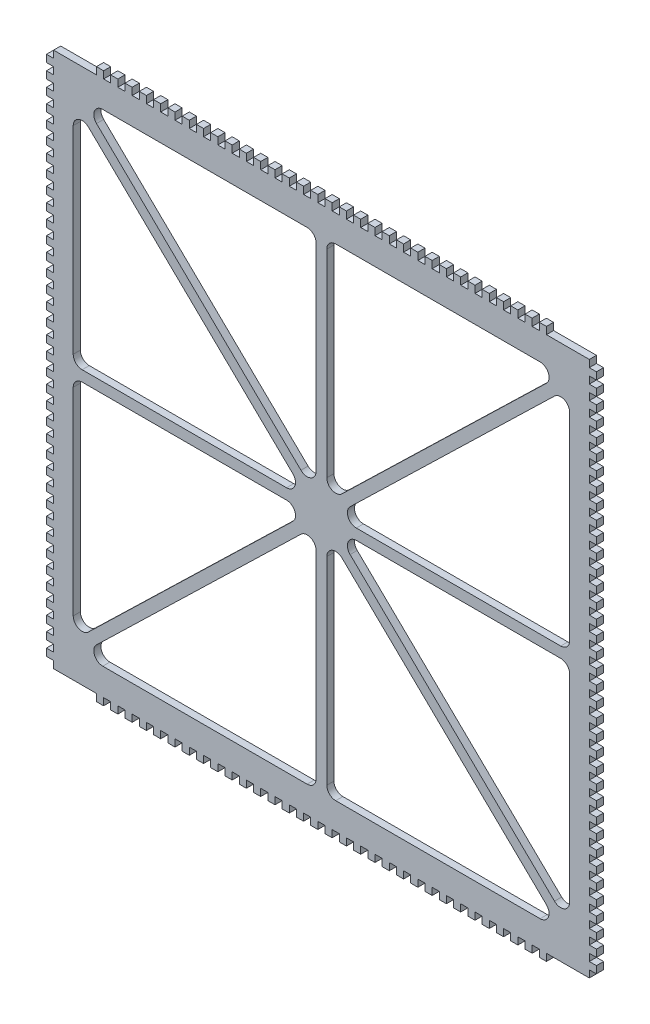
from build123d import *

# Parameters (mm, degrees)
SKETCH1_W           = 308
SKETCH1_H           = 300
BOSS_EXTRUDE1_DEPTH = 4
SKETCH2_W           = 4
SKETCH2_H           = 4
CUT_EXTRUDE1_DEPTH  = 4
SKETCH3_W           = 4
SKETCH3_H           = 4
BOSS_EXTRUDE2_DEPTH = 4


with BuildPart() as part:
    # Sketch1 → Boss-Extrude1 (new body)
    with BuildSketch(Plane.XY):
        Rectangle(SKETCH1_W, SKETCH1_H)
        with BuildLine():
            Line((-122.477093381, 135), (-8, 135))
            ThreePointArc((-8, 135), (-4.464466094, 133.535533906), (-3, 130))
            Line((-3, 130), (-3, 19.113899965))
            ThreePointArc((-3, 19.113899965), (-6.049843741, 14.509891867), (-11.478756226, 15.522485881))
            Line((-11.478756226, 15.522485881), (-125.955849607, 126.408585916))
            ThreePointArc((-125.955849607, 126.408585916), (-127.111587443, 131.876556631), (-122.477093381, 135))
        make_face(mode=Mode.SUBTRACT)
        with BuildLine():
            Line((-130.521243774, 122.477514119), (-16.044150393, 11.591414084))
            ThreePointArc((-16.044150393, 11.591414084), (-14.888412557, 6.123443369), (-19.522906619, 3))
            Line((-19.522906619, 3), (-134, 3))
            ThreePointArc((-134, 3), (-137.535533906, 4.464466094), (-139, 8))
            Line((-139, 8), (-139, 118.886100035))
            ThreePointArc((-139, 118.886100035), (-135.950156259, 123.490108133), (-130.521243774, 122.477514119))
        make_face(mode=Mode.SUBTRACT)
        with BuildLine():
            Line((8, 135), (122.477093381, 135))
            ThreePointArc((122.477093381, 135), (127.111587443, 131.876556631), (125.955849607, 126.408585916))
            Line((125.955849607, 126.408585916), (11.478756226, 15.522485881))
            ThreePointArc((11.478756226, 15.522485881), (6.049843741, 14.509891867), (3, 19.113899965))
            Line((3, 19.113899965), (3, 130))
            ThreePointArc((3, 130), (4.464466094, 133.535533906), (8, 135))
        make_face(mode=Mode.SUBTRACT)
        with BuildLine():
            Line((130.521243774, 122.477514119), (16.044150393, 11.591414084))
            ThreePointArc((16.044150393, 11.591414084), (14.888412557, 6.123443369), (19.522906619, 3))
            Line((19.522906619, 3), (134, 3))
            ThreePointArc((134, 3), (137.535533906, 4.464466094), (139, 8))
            Line((139, 8), (139, 118.886100035))
            ThreePointArc((139, 118.886100035), (135.950156259, 123.490108133), (130.521243774, 122.477514119))
        make_face(mode=Mode.SUBTRACT)
        with BuildLine():
            Line((-139, -8), (-139, -118.886100035))
            ThreePointArc((-139, -118.886100035), (-135.950156259, -123.490108133), (-130.521243774, -122.477514119))
            Line((-130.521243774, -122.477514119), (-16.044150393, -11.591414084))
            ThreePointArc((-16.044150393, -11.591414084), (-14.888412557, -6.123443369), (-19.522906619, -3))
            Line((-19.522906619, -3), (-134, -3))
            ThreePointArc((-134, -3), (-137.535533906, -4.464466094), (-139, -8))
        make_face(mode=Mode.SUBTRACT)
        with BuildLine():
            Line((139, -8), (139, -118.886100035))
            ThreePointArc((139, -118.886100035), (135.950156259, -123.490108133), (130.521243774, -122.477514119))
            Line((130.521243774, -122.477514119), (16.044150393, -11.591414084))
            ThreePointArc((16.044150393, -11.591414084), (14.888412557, -6.123443369), (19.522906619, -3))
            Line((19.522906619, -3), (134, -3))
            ThreePointArc((134, -3), (137.535533906, -4.464466094), (139, -8))
        make_face(mode=Mode.SUBTRACT)
        with BuildLine():
            Line((11.478756226, -15.522485881), (125.955849607, -126.408585916))
            ThreePointArc((125.955849607, -126.408585916), (127.111587443, -131.876556631), (122.477093381, -135))
            Line((122.477093381, -135), (8, -135))
            ThreePointArc((8, -135), (4.464466094, -133.535533906), (3, -130))
            Line((3, -130), (3, -19.113899965))
            ThreePointArc((3, -19.113899965), (6.049843741, -14.509891867), (11.478756226, -15.522485881))
        make_face(mode=Mode.SUBTRACT)
        with BuildLine():
            Line((-3, -19.113899965), (-3, -130))
            ThreePointArc((-3, -130), (-4.464466094, -133.535533906), (-8, -135))
            Line((-8, -135), (-122.477093381, -135))
            ThreePointArc((-122.477093381, -135), (-127.111587443, -131.876556631), (-125.955849607, -126.408585916))
            Line((-125.955849607, -126.408585916), (-11.478756226, -15.522485881))
            ThreePointArc((-11.478756226, -15.522485881), (-6.049843741, -14.509891867), (-3, -19.113899965))
        make_face(mode=Mode.SUBTRACT)
    extrude(amount=BOSS_EXTRUDE1_DEPTH)

    # Sketch2 → Cut-Extrude1 (cut)
    with BuildSketch(Plane.XY.offset(4)):
        with Locations((-152, 4)):
            Rectangle(SKETCH2_W, SKETCH2_H)
        with Locations((-152, 140)):
            Rectangle(SKETCH2_W, SKETCH2_H)
        with Locations((-152, 132)):
            Rectangle(SKETCH2_W, SKETCH2_H)
        with Locations((-152, 124)):
            Rectangle(SKETCH2_W, SKETCH2_H)
        with Locations((-152, 116)):
            Rectangle(SKETCH2_W, SKETCH2_H)
        with Locations((-152, 108)):
            Rectangle(SKETCH2_W, SKETCH2_H)
        with Locations((-152, 100)):
            Rectangle(SKETCH2_W, SKETCH2_H)
        with Locations((-152, 92)):
            Rectangle(SKETCH2_W, SKETCH2_H)
        with Locations((-152, 84)):
            Rectangle(SKETCH2_W, SKETCH2_H)
        with Locations((-152, 76)):
            Rectangle(SKETCH2_W, SKETCH2_H)
        with Locations((-152, 68)):
            Rectangle(SKETCH2_W, SKETCH2_H)
        with Locations((-152, 60)):
            Rectangle(SKETCH2_W, SKETCH2_H)
        with Locations((-152, 52)):
            Rectangle(SKETCH2_W, SKETCH2_H)
        with Locations((-152, 44)):
            Rectangle(SKETCH2_W, SKETCH2_H)
        with Locations((-152, 36)):
            Rectangle(SKETCH2_W, SKETCH2_H)
        with Locations((-152, 28)):
            Rectangle(SKETCH2_W, SKETCH2_H)
        with Locations((-152, 20)):
            Rectangle(SKETCH2_W, SKETCH2_H)
        with Locations((-152, 12)):
            Rectangle(SKETCH2_W, SKETCH2_H)
        with Locations((152, -140)):
            Rectangle(SKETCH2_W, SKETCH2_H)
        with Locations((-152, -140)):
            Rectangle(SKETCH2_W, SKETCH2_H)
        with Locations((152, -132)):
            Rectangle(SKETCH2_W, SKETCH2_H)
        with Locations((152, -124)):
            Rectangle(SKETCH2_W, SKETCH2_H)
        with Locations((152, -116)):
            Rectangle(SKETCH2_W, SKETCH2_H)
        with Locations((152, -108)):
            Rectangle(SKETCH2_W, SKETCH2_H)
        with Locations((152, -100)):
            Rectangle(SKETCH2_W, SKETCH2_H)
        with Locations((152, -92)):
            Rectangle(SKETCH2_W, SKETCH2_H)
        with Locations((152, -84)):
            Rectangle(SKETCH2_W, SKETCH2_H)
        with Locations((-152, 148)):
            Rectangle(SKETCH2_W, SKETCH2_H)
        with Locations((152, -76)):
            Rectangle(SKETCH2_W, SKETCH2_H)
        with Locations((152, -68)):
            Rectangle(SKETCH2_W, SKETCH2_H)
        with Locations((152, -60)):
            Rectangle(SKETCH2_W, SKETCH2_H)
        with Locations((152, -52)):
            Rectangle(SKETCH2_W, SKETCH2_H)
        with Locations((152, -44)):
            Rectangle(SKETCH2_W, SKETCH2_H)
        with Locations((152, -36)):
            Rectangle(SKETCH2_W, SKETCH2_H)
        with Locations((152, -28)):
            Rectangle(SKETCH2_W, SKETCH2_H)
        with Locations((152, -20)):
            Rectangle(SKETCH2_W, SKETCH2_H)
        with Locations((152, -12)):
            Rectangle(SKETCH2_W, SKETCH2_H)
        with Locations((152, -4)):
            Rectangle(SKETCH2_W, SKETCH2_H)
        with Locations((-152, -4)):
            Rectangle(SKETCH2_W, SKETCH2_H)
        with Locations((-152, -12)):
            Rectangle(SKETCH2_W, SKETCH2_H)
        with Locations((-152, -20)):
            Rectangle(SKETCH2_W, SKETCH2_H)
        with Locations((-152, -28)):
            Rectangle(SKETCH2_W, SKETCH2_H)
        with Locations((-152, -36)):
            Rectangle(SKETCH2_W, SKETCH2_H)
        with Locations((152, 4)):
            Rectangle(SKETCH2_W, SKETCH2_H)
        with Locations((152, 148)):
            Rectangle(SKETCH2_W, SKETCH2_H)
        with Locations((152, 12)):
            Rectangle(SKETCH2_W, SKETCH2_H)
        with Locations((152, 20)):
            Rectangle(SKETCH2_W, SKETCH2_H)
        with Locations((152, 28)):
            Rectangle(SKETCH2_W, SKETCH2_H)
        with Locations((152, 36)):
            Rectangle(SKETCH2_W, SKETCH2_H)
        with Locations((152, 44)):
            Rectangle(SKETCH2_W, SKETCH2_H)
        with Locations((-152, -44)):
            Rectangle(SKETCH2_W, SKETCH2_H)
        with Locations((-152, -52)):
            Rectangle(SKETCH2_W, SKETCH2_H)
        with Locations((-152, -60)):
            Rectangle(SKETCH2_W, SKETCH2_H)
        with Locations((-152, -68)):
            Rectangle(SKETCH2_W, SKETCH2_H)
        with Locations((-152, -76)):
            Rectangle(SKETCH2_W, SKETCH2_H)
        with Locations((-152, -84)):
            Rectangle(SKETCH2_W, SKETCH2_H)
        with Locations((152, 52)):
            Rectangle(SKETCH2_W, SKETCH2_H)
        with Locations((152, 60)):
            Rectangle(SKETCH2_W, SKETCH2_H)
        with Locations((152, 68)):
            Rectangle(SKETCH2_W, SKETCH2_H)
        with Locations((152, 76)):
            Rectangle(SKETCH2_W, SKETCH2_H)
        with Locations((152, 84)):
            Rectangle(SKETCH2_W, SKETCH2_H)
        with Locations((152, 92)):
            Rectangle(SKETCH2_W, SKETCH2_H)
        with Locations((-152, -92)):
            Rectangle(SKETCH2_W, SKETCH2_H)
        with Locations((-152, -100)):
            Rectangle(SKETCH2_W, SKETCH2_H)
        with Locations((-152, -108)):
            Rectangle(SKETCH2_W, SKETCH2_H)
        with Locations((152, 100)):
            Rectangle(SKETCH2_W, SKETCH2_H)
        with Locations((152, 108)):
            Rectangle(SKETCH2_W, SKETCH2_H)
        with Locations((152, 116)):
            Rectangle(SKETCH2_W, SKETCH2_H)
        with Locations((-152, -116)):
            Rectangle(SKETCH2_W, SKETCH2_H)
        with Locations((-152, -124)):
            Rectangle(SKETCH2_W, SKETCH2_H)
        with Locations((-152, -132)):
            Rectangle(SKETCH2_W, SKETCH2_H)
        with Locations((-152, -148)):
            Rectangle(SKETCH2_W, SKETCH2_H)
        with Locations((152, 124)):
            Rectangle(SKETCH2_W, SKETCH2_H)
        with Locations((152, 132)):
            Rectangle(SKETCH2_W, SKETCH2_H)
        with Locations((152, 140)):
            Rectangle(SKETCH2_W, SKETCH2_H)
        with Locations((152, -148)):
            Rectangle(SKETCH2_W, SKETCH2_H)
    extrude(amount=-CUT_EXTRUDE1_DEPTH, mode=Mode.SUBTRACT)

    # Sketch3 → Boss-Extrude2 (add)
    with BuildSketch(Plane.XY.offset(4)):
        with Locations((-12, 152)):
            Rectangle(SKETCH3_W, SKETCH3_H)
        with Locations((-4, 152)):
            Rectangle(SKETCH3_W, SKETCH3_H)
        with Locations((-20, 152)):
            Rectangle(SKETCH3_W, SKETCH3_H)
        with Locations((-28, 152)):
            Rectangle(SKETCH3_W, SKETCH3_H)
        with Locations((-36, 152)):
            Rectangle(SKETCH3_W, SKETCH3_H)
        with Locations((-44, 152)):
            Rectangle(SKETCH3_W, SKETCH3_H)
        with Locations((-52, 152)):
            Rectangle(SKETCH3_W, SKETCH3_H)
        with Locations((-60, 152)):
            Rectangle(SKETCH3_W, SKETCH3_H)
        with Locations((-68, 152)):
            Rectangle(SKETCH3_W, SKETCH3_H)
        with Locations((-76, 152)):
            Rectangle(SKETCH3_W, SKETCH3_H)
        with Locations((-84, 152)):
            Rectangle(SKETCH3_W, SKETCH3_H)
        with Locations((-92, 152)):
            Rectangle(SKETCH3_W, SKETCH3_H)
        with Locations((-100, 152)):
            Rectangle(SKETCH3_W, SKETCH3_H)
        with Locations((-108, 152)):
            Rectangle(SKETCH3_W, SKETCH3_H)
        with Locations((-116, 152)):
            Rectangle(SKETCH3_W, SKETCH3_H)
        with Locations((-124, 152)):
            Rectangle(SKETCH3_W, SKETCH3_H)
        with Locations((124, 152)):
            Rectangle(SKETCH3_W, SKETCH3_H)
        with Locations((116, 152)):
            Rectangle(SKETCH3_W, SKETCH3_H)
        with Locations((108, 152)):
            Rectangle(SKETCH3_W, SKETCH3_H)
        with Locations((100, 152)):
            Rectangle(SKETCH3_W, SKETCH3_H)
        with Locations((92, 152)):
            Rectangle(SKETCH3_W, SKETCH3_H)
        with Locations((84, 152)):
            Rectangle(SKETCH3_W, SKETCH3_H)
        with Locations((76, 152)):
            Rectangle(SKETCH3_W, SKETCH3_H)
        with Locations((68, 152)):
            Rectangle(SKETCH3_W, SKETCH3_H)
        with Locations((60, 152)):
            Rectangle(SKETCH3_W, SKETCH3_H)
        with Locations((52, 152)):
            Rectangle(SKETCH3_W, SKETCH3_H)
        with Locations((44, 152)):
            Rectangle(SKETCH3_W, SKETCH3_H)
        with Locations((36, 152)):
            Rectangle(SKETCH3_W, SKETCH3_H)
        with Locations((28, 152)):
            Rectangle(SKETCH3_W, SKETCH3_H)
        with Locations((20, 152)):
            Rectangle(SKETCH3_W, SKETCH3_H)
        with Locations((12, 152)):
            Rectangle(SKETCH3_W, SKETCH3_H)
        with Locations((4, 152)):
            Rectangle(SKETCH3_W, SKETCH3_H)
        with Locations((12, -152)):
            Rectangle(SKETCH3_W, SKETCH3_H)
        with Locations((4, -152)):
            Rectangle(SKETCH3_W, SKETCH3_H)
        with Locations((20, -152)):
            Rectangle(SKETCH3_W, SKETCH3_H)
        with Locations((28, -152)):
            Rectangle(SKETCH3_W, SKETCH3_H)
        with Locations((36, -152)):
            Rectangle(SKETCH3_W, SKETCH3_H)
        with Locations((44, -152)):
            Rectangle(SKETCH3_W, SKETCH3_H)
        with Locations((52, -152)):
            Rectangle(SKETCH3_W, SKETCH3_H)
        with Locations((60, -152)):
            Rectangle(SKETCH3_W, SKETCH3_H)
        with Locations((68, -152)):
            Rectangle(SKETCH3_W, SKETCH3_H)
        with Locations((76, -152)):
            Rectangle(SKETCH3_W, SKETCH3_H)
        with Locations((84, -152)):
            Rectangle(SKETCH3_W, SKETCH3_H)
        with Locations((92, -152)):
            Rectangle(SKETCH3_W, SKETCH3_H)
        with Locations((100, -152)):
            Rectangle(SKETCH3_W, SKETCH3_H)
        with Locations((108, -152)):
            Rectangle(SKETCH3_W, SKETCH3_H)
        with Locations((116, -152)):
            Rectangle(SKETCH3_W, SKETCH3_H)
        with Locations((124, -152)):
            Rectangle(SKETCH3_W, SKETCH3_H)
        with Locations((-124, -152)):
            Rectangle(SKETCH3_W, SKETCH3_H)
        with Locations((-116, -152)):
            Rectangle(SKETCH3_W, SKETCH3_H)
        with Locations((-108, -152)):
            Rectangle(SKETCH3_W, SKETCH3_H)
        with Locations((-100, -152)):
            Rectangle(SKETCH3_W, SKETCH3_H)
        with Locations((-92, -152)):
            Rectangle(SKETCH3_W, SKETCH3_H)
        with Locations((-84, -152)):
            Rectangle(SKETCH3_W, SKETCH3_H)
        with Locations((-76, -152)):
            Rectangle(SKETCH3_W, SKETCH3_H)
        with Locations((-68, -152)):
            Rectangle(SKETCH3_W, SKETCH3_H)
        with Locations((-60, -152)):
            Rectangle(SKETCH3_W, SKETCH3_H)
        with Locations((-52, -152)):
            Rectangle(SKETCH3_W, SKETCH3_H)
        with Locations((-44, -152)):
            Rectangle(SKETCH3_W, SKETCH3_H)
        with Locations((-36, -152)):
            Rectangle(SKETCH3_W, SKETCH3_H)
        with Locations((-28, -152)):
            Rectangle(SKETCH3_W, SKETCH3_H)
        with Locations((-20, -152)):
            Rectangle(SKETCH3_W, SKETCH3_H)
        with Locations((-12, -152)):
            Rectangle(SKETCH3_W, SKETCH3_H)
        with Locations((-4, -152)):
            Rectangle(SKETCH3_W, SKETCH3_H)
    extrude(amount=-BOSS_EXTRUDE2_DEPTH)


solid = part.part
